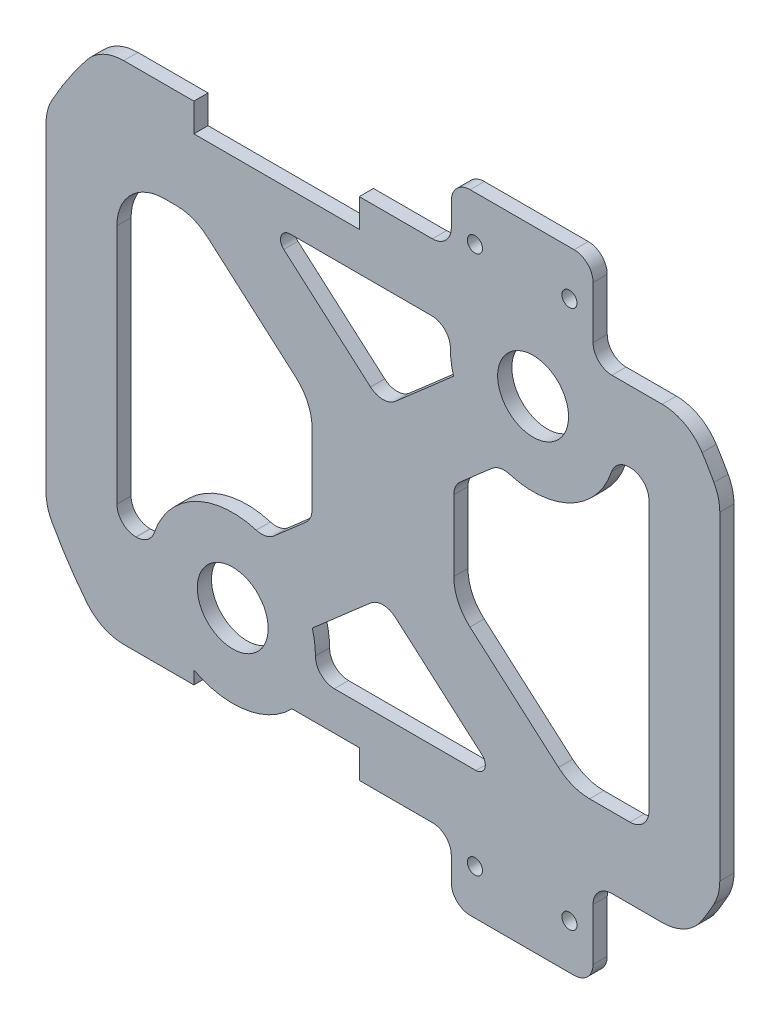
from build123d import *

# Parameters (mm, degrees)
ESBO_O1_R                = 7.5
ESBO_O1_R_2              = 1.6
RESSALTO_EXTRUS_O1_DEPTH = 3
FILETE2_R                = 10
FILETE3_R                = 4
FILETE4_R                = 2


with BuildPart() as part:
    # Esboço1 → Ressalto-extrusão1 (new body)
    with BuildSketch(Plane.XY):
        with BuildLine():
            Line((14.471901241, -53.5), (14.471901241, -66.5))
            Line((14.471901241, -66.5), (44.471901241, -66.5))
            Line((44.471901241, -66.5), (44.471901241, -47.5))
            Line((44.471901241, -47.5), (64.371965948, -47.5))
            ThreePointArc((64.371965948, -47.5), (68.06268346, -42.041302552), (71.291651246, -36.297389198))
            Line((71.291651246, -36.297389198), (71.291651246, 36.297389198))
            ThreePointArc((71.291651246, 36.297389198), (68.06268346, 42.041302552), (64.371965948, 47.5))
            Line((64.371965948, 47.5), (44.471901241, 47.5))
            Line((44.471901241, 47.5), (44.471901241, 66.5))
            Line((44.471901241, 66.5), (14.471901241, 66.5))
            Line((14.471901241, 66.5), (14.471901241, 53.5))
            Line((14.471901241, 53.5), (-5.003543323, 53.5))
            Line((-5.003543323, 53.5), (-5.003543323, 47.5))
            Line((-5.003543323, 47.5), (-40.003543323, 47.5))
            Line((-40.003543323, 47.5), (-40.003543323, 53.5))
            Line((-40.003543323, 53.5), (-59.478987886, 53.5))
            ThreePointArc((-59.478987886, 53.5), (-65.948635083, 45.285511266), (-71.291651246, 36.297389198))
            Line((-71.291651246, 36.297389198), (-71.291651246, -36.297389198))
            ThreePointArc((-71.291651246, -36.297389198), (-65.948635083, -45.285511266), (-59.478987886, -53.5))
            Line((-59.478987886, -53.5), (-40.003543323, -53.5))
            Line((-40.003543323, -53.5), (-40.003543323, -50.748788204))
            ThreePointArc((-40.003543323, -50.748788204), (-29.078718374, -52.589059769), (-19.237993286, -47.5))
            Line((-19.237993286, -47.5), (-5.003543323, -47.5))
            Line((-5.003543323, -47.5), (-5.003543323, -53.5))
            Line((-5.003543323, -53.5), (14.471901241, -53.5))
        make_face()
        with Locations((-31.783703802, -35.29937921)):
            Circle(ESBO_O1_R, mode=Mode.SUBTRACT)
        with Locations((19.471901241, -57)):
            Circle(ESBO_O1_R_2, mode=Mode.SUBTRACT)
        with Locations((39.471901241, -57)):
            Circle(ESBO_O1_R_2, mode=Mode.SUBTRACT)
        with BuildLine():
            Line((25, -39.332538239), (-14.754798134, -39.332538239))
            ThreePointArc((-14.754798134, -39.332538239), (-14.287636143, -34.928412284), (-14.941054623, -30.548045856))
            Line((-14.941054623, -30.548045856), (0, -17.5))
            Line((0, -17.5), (25, -39.332538239))
        make_face(mode=Mode.SUBTRACT)
        with BuildLine():
            Line((-15, -10.684767074), (-24.807750727, -19.249890785))
            ThreePointArc((-24.807750727, -19.249890785), (-40.174599446, -19.942202702), (-49.058352164, -32.5))
            Line((-49.058352164, -32.5), (-56.291651246, -32.5))
            Line((-56.291651246, -32.5), (-56.291651246, 32.5))
            Line((-56.291651246, 32.5), (-39.980184035, 32.5))
            Line((-39.980184035, 32.5), (-15, 10.684767074))
            Line((-15, 10.684767074), (-15, -10.684767074))
        make_face(mode=Mode.SUBTRACT)
        with BuildLine():
            Line((49.058352164, 32.5), (56.291651246, 32.5))
            Line((56.291651246, 32.5), (56.291651246, -32.5))
            Line((56.291651246, -32.5), (39.980184035, -32.5))
            Line((39.980184035, -32.5), (15, -10.684767074))
            Line((15, -10.684767074), (15, 10.684767074))
            Line((15, 10.684767074), (24.807750727, 19.249890785))
            ThreePointArc((24.807750727, 19.249890785), (40.174599446, 19.942202702), (49.058352164, 32.5))
        make_face(mode=Mode.SUBTRACT)
        with BuildLine():
            Line((0, 17.5), (-25, 39.332538239))
            Line((-25, 39.332538239), (14.754798134, 39.332538239))
            ThreePointArc((14.754798134, 39.332538239), (14.287636143, 34.928412284), (14.941054623, 30.548045856))
            Line((14.941054623, 30.548045856), (0, 17.5))
        make_face(mode=Mode.SUBTRACT)
        with Locations((19.471901241, 57)):
            Circle(ESBO_O1_R_2, mode=Mode.SUBTRACT)
        with Locations((39.471901241, 57)):
            Circle(ESBO_O1_R_2, mode=Mode.SUBTRACT)
        with Locations((31.783703802, 35.29937921)):
            Circle(ESBO_O1_R, mode=Mode.SUBTRACT)
    extrude(amount=RESSALTO_EXTRUS_O1_DEPTH)

    # Filete2
    filete2_edges = [part.edges().sort_by_distance(p)[0] for p in [
        (-15, 10.684767074, 1.5),
        (-39.980184035, 32.5, 1.5),
        (-56.291651246, 32.5, 1.5),
        (-59.478987886, -53.5, 1.5),
        (-71.291651246, -36.297389198, 1.5),
        (-71.291651246, 36.297389198, 1.5),
        (-59.478987886, 53.5, 1.5),
        (64.371965948, 47.5, 1.5),
        (71.291651246, 36.297389198, 1.5),
        (71.291651246, -36.297389198, 1.5),
        (64.371965948, -47.5, 1.5),
        (15, -10.684767074, 1.5),
        (39.980184035, -32.5, 1.5),
    ]]
    fillet(filete2_edges, radius=FILETE2_R)

    # Filete3
    filete3_edges = [part.edges().sort_by_distance(p)[0] for p in [
        (56.291651246, -32.5, 1.5),
        (56.291651246, 32.5, 1.5),
        (49.058352164, 32.5, 1.5),
        (24.807750727, 19.249890785, 1.5),
        (14.754798134, 39.332538239, 1.5),
        (0, 17.5, 1.5),
        (-15, -10.684767074, 1.5),
        (-56.291651246, -32.5, 1.5),
        (-49.058352164, -32.5, 1.5),
        (-24.807750727, -19.249890785, 1.5),
        (-14.754798134, -39.332538239, 1.5),
        (0, -17.5, 1.5),
        (14.471901241, 53.5, 1.5),
        (14.471901241, 66.5, 1.5),
        (44.471901241, 66.5, 1.5),
        (44.471901241, 47.5, 1.5),
        (44.471901241, -47.5, 1.5),
        (44.471901241, -66.5, 1.5),
        (14.471901241, -66.5, 1.5),
        (14.471901241, -53.5, 1.5),
        (15, 10.684767074, 1.5),
    ]]
    fillet(filete3_edges, radius=FILETE3_R)

    # Filete4
    filete4_edges = [part.edges().sort_by_distance(p)[0] for p in [
        (-25, 39.332538239, 1.5),
        (25, -39.332538239, 1.5),
    ]]
    fillet(filete4_edges, radius=FILETE4_R)


solid = part.part
